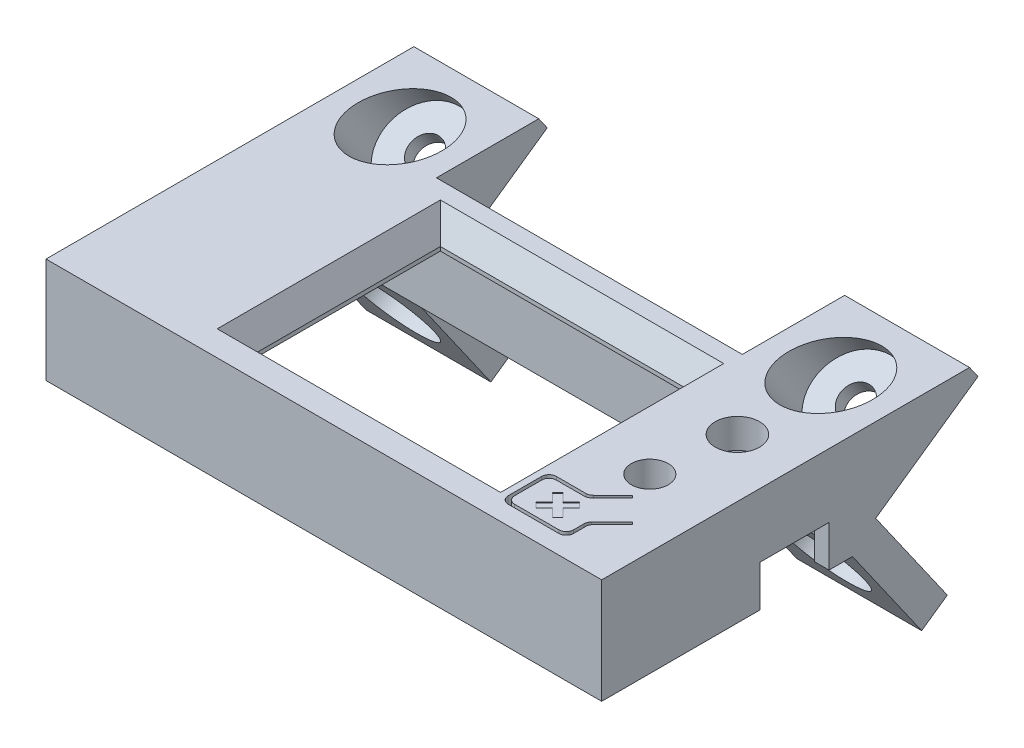
from build123d import *

# Parameters (mm, degrees)
SKETCH1_W               = 113
SKETCH1_H               = 54
BOSS_EXTRUDE1_DEPTH     = 10
SKETCH1_3_W             = 113
SKETCH1_3_H             = 54
SKETCH1_3_R             = 1.5
BOSS_EXTRUDE2_DEPTH     = 5.4
BOSS_EXTRUDE5_START     = 5.4
SKETCH1_4_W             = 113
SKETCH1_4_H             = 54
SKETCH1_4_R             = 3.75
SKETCH1_4_R_2           = 4.5
SKETCH1_4_W_2           = 51.62
SKETCH1_4_H_2           = 39.38
BOSS_EXTRUDE5_DEPTH     = 6
CUT_EXTRUDE_THIN1_START = 5.4
CUT_EXTRUDE_THIN1_DEPTH = 6
CUT_EXTRUDE1_DEPTH      = 5
FILLET1_R               = 1.5
CUT_EXTRUDE2_DEPTH      = 0.2
CHAMFER1_SIZE           = 3
CHAMFER1_SIZE2          = 5.196152423
SKETCH4_W               = 26.49
SKETCH4_H               = 4
CUT_EXTRUDE3_DEPTH      = 5
SKETCH5_W               = 14
SKETCH5_H               = 8.4
CUT_EXTRUDE4_DEPTH      = 5
BOSS_EXTRUDE6_DEPTH     = 25.4
SKETCH7_R               = 3.25
CUT_EXTRUDE5_DEPTH      = 46.907223847
CUT_EXTRUDE8_START      = -3
SKETCH7_4_R             = 8.5
SKETCH7_4_R_2           = 3.25
CUT_EXTRUDE8_DEPTH      = 43.907223847
SKETCH8_R               = 3.25
CUT_EXTRUDE6_DEPTH      = 60.675369484
CUT_EXTRUDE9_START      = -3
SKETCH8_5_R             = 8.5
SKETCH8_5_R_2           = 3.25
CUT_EXTRUDE9_DEPTH      = 25.4
BOSS_EXTRUDE9_REACH     = 89.6


with BuildPart() as part:
    # Sketch1 → Boss-Extrude1 (new body)
    with BuildSketch(Plane(origin=(0, 0, 0), x_dir=(1, 0, 0), z_dir=(0, 1, 0))):
        Rectangle(SKETCH1_W, SKETCH1_H)
        Polygon((-53.5, -16.07179677), (-53.5, 16.07179677), (-53.5, 24), (-45.57179677, 24), (45.57179677, 24), (53.5, 24), (53.5, 16.07179677), (53.5, -16.07179677), (53.5, -24), (45.57179677, -24), (-45.57179677, -24), (-53.5, -24), align=None, mode=Mode.SUBTRACT)
    extrude(amount=-BOSS_EXTRUDE1_DEPTH)

    # Sketch1_3 → Boss-Extrude2 (add)
    with BuildSketch(Plane(origin=(0, 0, 0), x_dir=(1, 0, 0), z_dir=(0, 1, 0))):
        Rectangle(SKETCH1_3_W, SKETCH1_3_H)
        Polygon((-53.5, -16.07179677), (-53.5, 16.07179677), (-53.5, 24), (-45.57179677, 24), (45.57179677, 24), (53.5, 24), (53.5, 16.07179677), (53.5, -16.07179677), (53.5, -24), (45.57179677, -24), (-45.57179677, -24), (-53.5, -24), align=None, mode=Mode.SUBTRACT)
        with BuildLine():
            Line((-53.5, 24), (-53.5, 16.07179677))
            ThreePointArc((-53.5, 16.07179677), (-47.550252532, 18.050252532), (-45.57179677, 24))
            Line((-45.57179677, 24), (-53.5, 24))
        make_face()
        with Locations((-50.4, 20.575)):
            Circle(SKETCH1_3_R, mode=Mode.SUBTRACT)
        with BuildLine():
            ThreePointArc((-45.57179677, -24), (-47.550252532, -18.050252532), (-53.5, -16.07179677))
            Line((-53.5, -16.07179677), (-53.5, -24))
            Line((-53.5, -24), (-45.57179677, -24))
        make_face()
        with Locations((-50.4, -20.575)):
            Circle(SKETCH1_3_R, mode=Mode.SUBTRACT)
        with BuildLine():
            Line((53.5, 24), (45.57179677, 24))
            ThreePointArc((45.57179677, 24), (47.550252532, 18.050252532), (53.5, 16.07179677))
            Line((53.5, 16.07179677), (53.5, 24))
        make_face()
        with Locations((50.4, 20.575)):
            Circle(SKETCH1_3_R, mode=Mode.SUBTRACT)
        with BuildLine():
            ThreePointArc((53.5, -16.07179677), (47.550252532, -18.050252532), (45.57179677, -24))
            Line((45.57179677, -24), (53.5, -24))
            Line((53.5, -24), (53.5, -16.07179677))
        make_face()
        with Locations((50.4, -20.575)):
            Circle(SKETCH1_3_R, mode=Mode.SUBTRACT)
    extrude(amount=BOSS_EXTRUDE2_DEPTH)

    # Sketch1_4 → Boss-Extrude5 (add)
    with BuildSketch(Plane(origin=(0, 0, 0), x_dir=(1, 0, 0), z_dir=(0, 1, 0)).offset(BOSS_EXTRUDE5_START)):
        Rectangle(SKETCH1_4_W, SKETCH1_4_H)
        with Locations((42.78, -3.495)):
            Circle(SKETCH1_4_R, mode=Mode.SUBTRACT)
        with Locations((44.69, 12.41)):
            Circle(SKETCH1_4_R_2, mode=Mode.SUBTRACT)
        with Locations((2.01, 0.81)):
            Rectangle(SKETCH1_4_W_2, SKETCH1_4_H_2, mode=Mode.SUBTRACT)
    extrude(amount=BOSS_EXTRUDE5_DEPTH)

    # Sketch1_5 → Cut-Extrude-Thin1 (cut)
    with BuildSketch(Plane(origin=(0, 0, 0), x_dir=(1, 0, 0), z_dir=(0, 1, 0)).offset(CUT_EXTRUDE_THIN1_START)):
        Polygon((49.424523111, -13.683696801), (44.828329033, -18.279890879), (44.828329033, -22.537250192), (32.828329033, -22.537250192), (32.828329033, -14.037250192), (40.585688346, -14.037250192), (45.181882424, -9.441056114), (44.722263016, -8.981436706), (40.316449531, -13.387250192), (32.178329033, -13.387250192), (32.178329033, -23.187250192), (45.478329033, -23.187250192), (45.478329033, -18.549129694), (49.884142519, -14.143316209), align=None)
    extrude(amount=CUT_EXTRUDE_THIN1_DEPTH, mode=Mode.SUBTRACT)

    # Sketch2 → Cut-Extrude1 (cut)
    with BuildSketch(Plane.XZ.offset(-5.4)):
        Polygon((32.828329033, 14.037250192), (32.828329033, 22.537250192), (44.828329033, 22.537250192), (44.828329033, 18.279890879), (49.424523111, 13.683696801), (45.181882424, 9.441056114), (40.585688346, 14.037250192), align=None)
    extrude(amount=-CUT_EXTRUDE1_DEPTH, mode=Mode.SUBTRACT)

    # Fillet1
    fillet1_edges = [part.edges().sort_by_distance(p)[0] for p in [
        (44.828329033, 10.9, 18.279890879),
        (44.828329033, 10.9, 22.537250192),
        (32.828329033, 10.9, 22.537250192),
        (32.828329033, 10.9, 14.037250192),
        (40.585688346, 10.9, 14.037250192),
        (40.316449531, 8.4, 13.387250192),
        (32.178329033, 8.4, 13.387250192),
        (32.178329033, 8.4, 23.187250192),
        (45.478329033, 8.4, 23.187250192),
        (45.478329033, 8.4, 18.549129694),
    ]]
    fillet(fillet1_edges, radius=FILLET1_R)

    # Sketch3 → Cut-Extrude2 (cut)
    with BuildSketch(Plane(origin=(0, 11.4, 0), x_dir=(1, 0, 0), z_dir=(0, 1, 0))):
        Polygon((37.138989205, -15.537250192), (38.828329033, -17.22659002), (40.517668861, -15.537250192), (41.578329033, -16.597910363), (39.888989205, -18.287250192), (41.578329033, -19.97659002), (40.517668861, -21.037250192), (38.828329033, -19.347910363), (37.138989205, -21.037250192), (36.078329033, -19.97659002), (37.767668861, -18.287250192), (36.078329033, -16.597910363), align=None)
    extrude(amount=-CUT_EXTRUDE2_DEPTH, mode=Mode.SUBTRACT)

    # Chamfer1
    chamfer1_edges = [part.edges().sort_by_distance(p)[0] for p in [
        (-23.8, 11.4, -0.81),
        (2.01, 11.4, 18.88),
        (27.82, 11.4, -0.81),
        (2.01, 11.4, -20.5),
    ]]
    chamfer1_side = [part.faces().sort_by_distance(p)[0] for p in [
        (0, 11.4, -25.7476023),
    ]]
    chamfer(chamfer1_edges, length=CHAMFER1_SIZE, length2=CHAMFER1_SIZE2, reference=chamfer1_side[0])

    # Sketch4 → Cut-Extrude3 (cut)
    with BuildSketch(Plane.ZY.offset(56.5)):
        with Locations((1.895, -3.6)):
            Rectangle(SKETCH4_W, SKETCH4_H)
    extrude(amount=-CUT_EXTRUDE3_DEPTH, mode=Mode.SUBTRACT)

    # Sketch5 → Cut-Extrude4 (cut)
    with BuildSketch(Plane(origin=(56.5, 0, 0), x_dir=(0, 0, -1), z_dir=(1, 0, 0))):
        with Locations((12.23, -5.8)):
            Rectangle(SKETCH5_W, SKETCH5_H)
    extrude(amount=-CUT_EXTRUDE4_DEPTH, mode=Mode.SUBTRACT)

    # Sketch6 → Boss-Extrude6 (add)
    with BuildSketch(Plane(origin=(56.5, 0, 0), x_dir=(0, 0, -1), z_dir=(1, 0, 0))):
        Polygon((47.806461925, 11.4), (49.527191234, 8.942543867), (28.720729309, -5.626297616), (43.289570792, -26.432759541), (38.066945953, -30.089680823), (24, -10), (27, -10), (27, -3.168841483), (27, 11.4), align=None)
    boss_extrude6 = extrude(amount=-BOSS_EXTRUDE6_DEPTH)

    # Sketch7 → Cut-Extrude5 (cut, through all)
    with BuildSketch(Plane(origin=(0, -17.269631064, -12.092325853), x_dir=(1, 0, 0), z_dir=(0, -0.819152044, -0.573576436))):
        with Locations((43.8, -32.99953239)):
            Circle(SKETCH7_R)
    cut_extrude5 = extrude(amount=-CUT_EXTRUDE5_DEPTH, mode=Mode.SUBTRACT)

    # Sketch7_4 → Cut-Extrude8 (cut, through all)
    with BuildSketch(Plane(origin=(0, -17.269631064, -12.092325853), x_dir=(1, 0, 0), z_dir=(0, -0.819152044, -0.573576436)).offset(CUT_EXTRUDE8_START)):
        with Locations((43.8, -32.99953239)):
            Circle(SKETCH7_4_R)
        with Locations((43.8, -32.99953239)):
            Circle(SKETCH7_4_R_2, mode=Mode.SUBTRACT)
    cut_extrude8 = extrude(amount=-CUT_EXTRUDE8_DEPTH, mode=Mode.SUBTRACT)

    # Sketch8 → Cut-Extrude6 (cut, through all)
    with BuildSketch(Plane(origin=(0, 11.643333448, -16.628403456), x_dir=(-1, 0, 0), z_dir=(0, 0.573576436, -0.819152044))):
        with Locations((-43.8, -33.782326761)):
            Circle(SKETCH8_R)
    cut_extrude6 = extrude(amount=-CUT_EXTRUDE6_DEPTH, mode=Mode.SUBTRACT)

    # Sketch8_5 → Cut-Extrude9 (cut)
    with BuildSketch(Plane(origin=(0, 11.643333448, -16.628403456), x_dir=(-1, 0, 0), z_dir=(0, 0.573576436, -0.819152044)).offset(CUT_EXTRUDE9_START)):
        with Locations((-43.8, -33.782326761)):
            Circle(SKETCH8_5_R)
        with Locations((-43.8, -33.782326761)):
            Circle(SKETCH8_5_R_2, mode=Mode.SUBTRACT)
    cut_extrude9 = extrude(amount=-CUT_EXTRUDE9_DEPTH, mode=Mode.SUBTRACT)

    # Mirror1: Boss-Extrude6, Cut-Extrude5, Cut-Extrude8, Cut-Extrude6, Cut-Extrude9 across plane
    add(boss_extrude6.mirror(Plane(origin=(0, 0, 0), x_dir=(0, 0, 1), z_dir=(1, 0, 0))))
    add(cut_extrude5.mirror(Plane(origin=(0, 0, 0), x_dir=(0, 0, 1), z_dir=(1, 0, 0))), mode=Mode.SUBTRACT)
    add(cut_extrude8.mirror(Plane(origin=(0, 0, 0), x_dir=(0, 0, 1), z_dir=(1, 0, 0))), mode=Mode.SUBTRACT)
    add(cut_extrude6.mirror(Plane(origin=(0, 0, 0), x_dir=(0, 0, 1), z_dir=(1, 0, 0))), mode=Mode.SUBTRACT)
    add(cut_extrude9.mirror(Plane(origin=(0, 0, 0), x_dir=(0, 0, 1), z_dir=(1, 0, 0))), mode=Mode.SUBTRACT)

    # Sketch9 → Boss-Extrude9 (add, up to next)
    with BuildSketch(Plane.ZY.offset(-31.1), mode=Mode.PRIVATE) as boss_extrude9_sk1:
        Polygon((-27, 11.4), (-35.565845727, -0.833295501), (-27, -6.83116525), align=None)
    boss_extrude9_tool1 = extrude(boss_extrude9_sk1.sketch, amount=BOSS_EXTRUDE9_REACH, mode=Mode.PRIVATE) - part.part
    add(boss_extrude9_tool1.solids().sort_by_distance((31.1, 1.24518, -29.855282))[0])


solid = part.part
